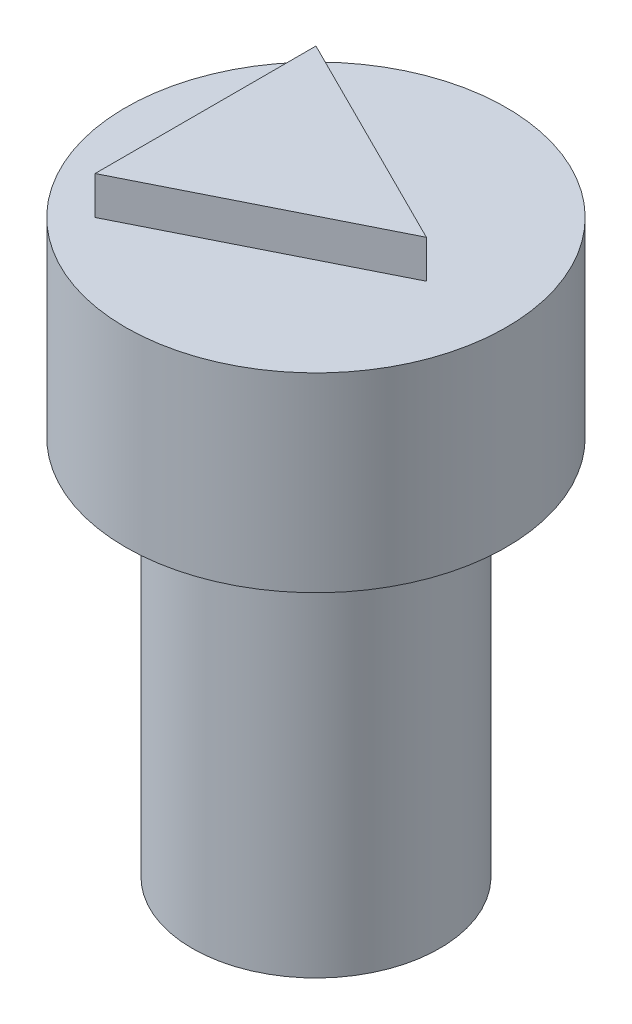
from build123d import *

# Parameters (mm, degrees)
SKETCH1_R           = 3.25
BOSS_EXTRUDE1_DEPTH = 10
SKETCH2_R           = 1.75
CUT_EXTRUDE1_DEPTH  = 2.5
SKETCH6_R           = 5
BOSS_EXTRUDE2_DEPTH = 5
BOSS_EXTRUDE3_DEPTH = 1


with BuildPart() as part:
    # Sketch1 → Boss-Extrude1 (new body)
    with BuildSketch(Plane(origin=(0, 0, 0), x_dir=(1, 0, 0), z_dir=(0, 1, 0))):
        Circle(SKETCH1_R)
    extrude(amount=BOSS_EXTRUDE1_DEPTH)

    # Sketch2 → Cut-Extrude1 (cut)
    with BuildSketch(Plane.XZ):
        Circle(SKETCH2_R)
    extrude(amount=-CUT_EXTRUDE1_DEPTH, mode=Mode.SUBTRACT)

    # Sketch6 → Boss-Extrude2 (add)
    with BuildSketch(Plane(origin=(0, 10, 0), x_dir=(1, 0, 0), z_dir=(0, 1, 0))):
        Circle(SKETCH6_R)
    extrude(amount=BOSS_EXTRUDE2_DEPTH)

    # Sketch9 → Boss-Extrude3 (add)
    with BuildSketch(Plane(origin=(0, 15, 0), x_dir=(1, 0, 0), z_dir=(0, 1, 0))):
        Polygon((-2.9, 2.9), (-2.9, -2.9), (2.9, 0), align=None)
    extrude(amount=BOSS_EXTRUDE3_DEPTH)


solid = part.part
